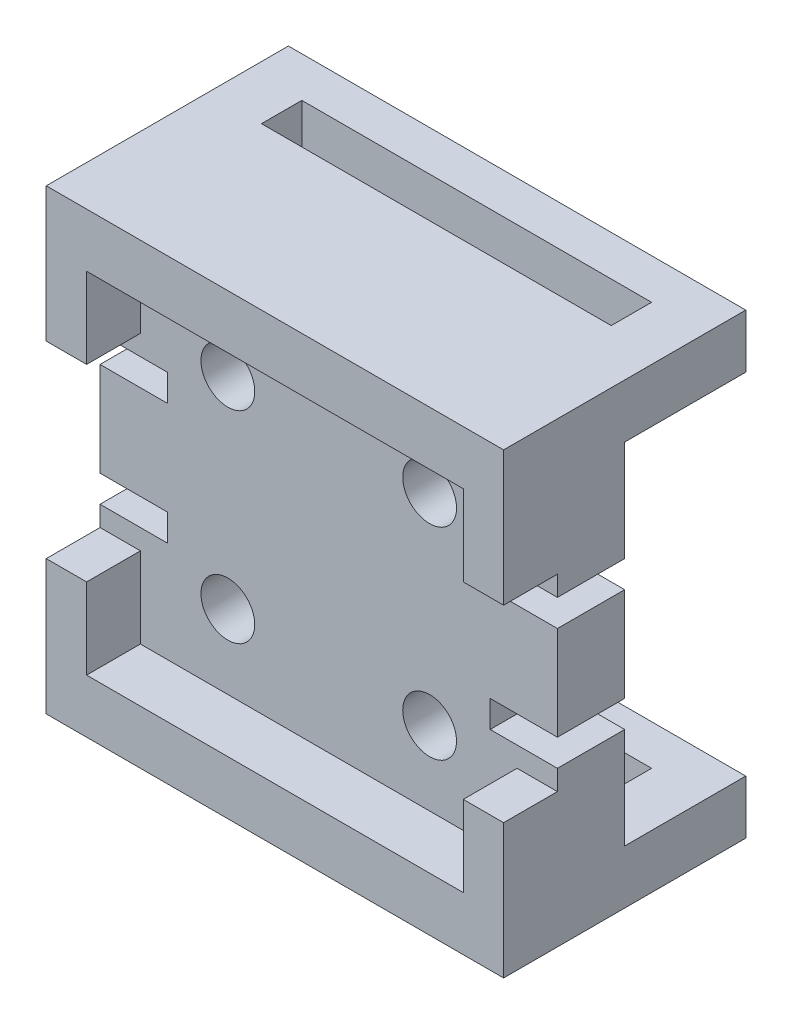
from build123d import *

# Parameters (mm, degrees)
SKETCH1_W          = 34
SKETCH1_H          = 34
SKETCH1_R          = 2
BODY_DEPTH         = 5
SKETCH2_W          = 34
SKETCH2_H          = 4
LEG1_DEPTH         = 3
SKETCH3_W          = 4
SKETCH3_H          = 4
LEG2_DEPTH         = 3
SKETCH4_W          = 34
SKETCH4_H          = 4
LEG3_DEPTH         = 3
WALLS_DEPTH        = 4
SKETCH6_W          = 5
SKETCH6_H          = 2
CUT_EXTRUDE1_DEPTH = 5


with BuildPart() as part:
    # Sketch1 → Body (new body)
    with BuildSketch(Plane.XY):
        with Locations((17, 17)):
            Rectangle(SKETCH1_W, SKETCH1_H)
        with Locations((24.5, 24.5)):
            Circle(SKETCH1_R, mode=Mode.SUBTRACT)
        with Locations((9.5, 24.5)):
            Circle(SKETCH1_R, mode=Mode.SUBTRACT)
        with Locations((9.5, 9.5)):
            Circle(SKETCH1_R, mode=Mode.SUBTRACT)
        with Locations((24.5, 9.5)):
            Circle(SKETCH1_R, mode=Mode.SUBTRACT)
    extrude(amount=BODY_DEPTH)

    # Sketch2 → Leg1 (add)
    with BuildSketch(Plane(origin=(0, 0, 0), x_dir=(-1, 0, 0), z_dir=(0, 0, -1))):
        with Locations((-17, 32)):
            Rectangle(SKETCH2_W, SKETCH2_H)
        with Locations((-17, 2)):
            Rectangle(SKETCH2_W, SKETCH2_H)
    extrude(amount=LEG1_DEPTH)

    # Sketch3 → Leg2 (add)
    with BuildSketch(Plane(origin=(0, 0, -3), x_dir=(-1, 0, 0), z_dir=(0, 0, -1))):
        with Locations((-32, 32)):
            Rectangle(SKETCH3_W, SKETCH3_H)
        with Locations((-2, 32)):
            Rectangle(SKETCH3_W, SKETCH3_H)
        with Locations((-2, 2)):
            Rectangle(SKETCH3_W, SKETCH3_H)
        with Locations((-32, 2)):
            Rectangle(SKETCH3_W, SKETCH3_H)
    extrude(amount=LEG2_DEPTH)

    # Sketch4 → Leg3 (add)
    with BuildSketch(Plane(origin=(0, 0, -6), x_dir=(-1, 0, 0), z_dir=(0, 0, -1))):
        with Locations((-17, 32)):
            Rectangle(SKETCH4_W, SKETCH4_H)
        with Locations((-17, 2)):
            Rectangle(SKETCH4_W, SKETCH4_H)
    extrude(amount=LEG3_DEPTH)

    # Sketch5 → Walls (add)
    with BuildSketch(Plane.XY.offset(5)):
        Polygon((0, 34), (34, 34), (34, 30), (34, 24), (31, 24), (31, 30), (3, 30), (3, 24), (0, 24), (0, 30), align=None)
        Polygon((31, 10), (34, 10), (34, 4), (34, 0), (0, 0), (0, 4), (0, 10), (3, 10), (3, 4), (31, 4), align=None)
    extrude(amount=WALLS_DEPTH)

    # Sketch6 → Cut-Extrude1 (cut)
    with BuildSketch(Plane.XY.offset(5)):
        with Locations((2.5, 21.5)):
            Rectangle(SKETCH6_W, SKETCH6_H)
        with Locations((31.5, 21.5)):
            Rectangle(SKETCH6_W, SKETCH6_H)
        with Locations((2.5, 12.5)):
            Rectangle(SKETCH6_W, SKETCH6_H)
        with Locations((31.5, 12.5)):
            Rectangle(SKETCH6_W, SKETCH6_H)
    extrude(amount=-CUT_EXTRUDE1_DEPTH, mode=Mode.SUBTRACT)


solid = part.part
